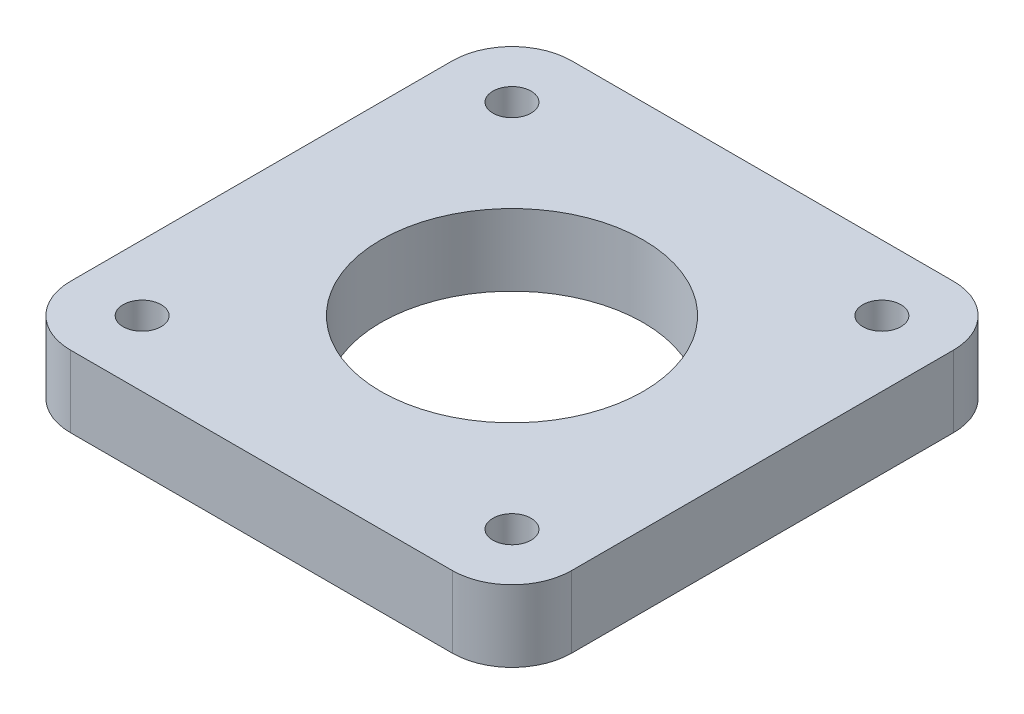
from build123d import *

# Parameters (mm, degrees)
SKETCH1_W            = 42
SKETCH1_H            = 42
BOSS_EXTRUDE1_DEPTH  = 6
M3_CLEARANCE_HOLE1_D = 3.2
SKETCH6_R            = 11
CUT_EXTRUDE3_DEPTH   = 7
FILLET1_R            = 5


with BuildPart() as part:
    # Sketch1 → Boss-Extrude1 (new body)
    with BuildSketch(Plane(origin=(0, 0, 0), x_dir=(1, 0, 0), z_dir=(0, 1, 0))):
        Rectangle(SKETCH1_W, SKETCH1_H)
    extrude(amount=BOSS_EXTRUDE1_DEPTH)

    # M3 Clearance Hole1 (through all)
    with Locations(Plane(origin=(0, 0, 0), x_dir=(0, 0, -1), z_dir=(0, -1, 0))):
        with Locations((15.5, -15.5), (-15.5, -15.5), (-15.5, 15.5), (15.5, 15.5)):
            Hole(M3_CLEARANCE_HOLE1_D / 2)

    # Sketch6 → Cut-Extrude3 (cut, through all)
    with BuildSketch(Plane(origin=(0, 0, 0), x_dir=(0, 0, 1), z_dir=(0, -1, 0))):
        Circle(SKETCH6_R)
    extrude(amount=-CUT_EXTRUDE3_DEPTH, mode=Mode.SUBTRACT)

    # Fillet1
    fillet1_edges = [part.edges().sort_by_distance(p)[0] for p in [
        (21, 3, 21),
        (-21, 3, 21),
        (-21, 3, -21),
        (21, 3, -21),
    ]]
    fillet(fillet1_edges, radius=FILLET1_R)


solid = part.part
